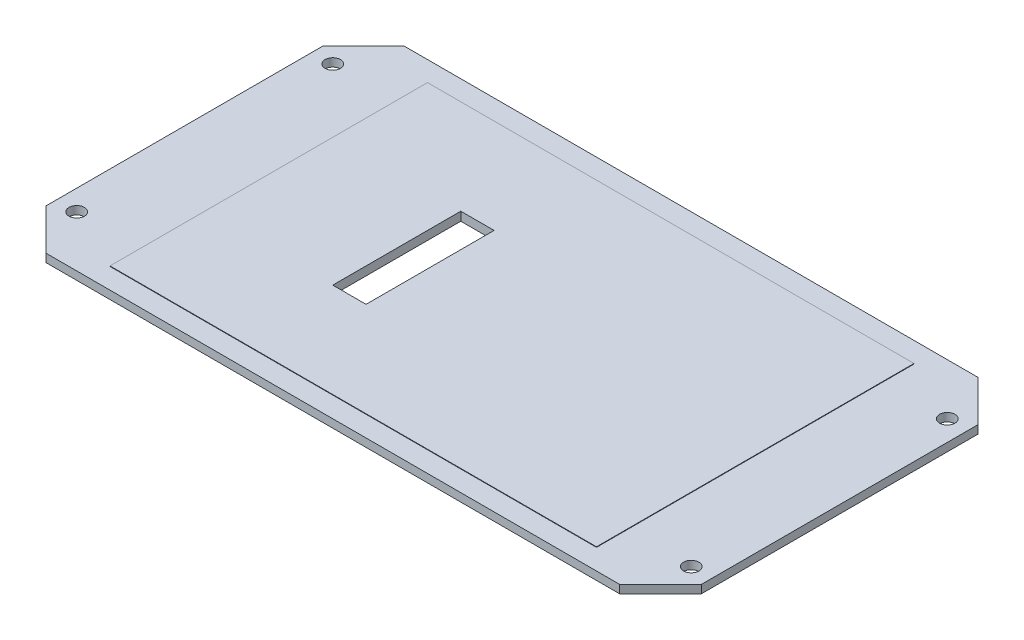
from build123d import *

# Parameters (mm, degrees)
SKETCH1_W                = 128
SKETCH1_H                = 70
BOSS_EXTRUDE1_DEPTH      = 1.6
CHAMFER1_SIZE            = 8
F_3_0_3_DIAMETER_HOLE1_D = 3
SKETCH4_W                = 95
SKETCH4_H                = 62
BOSS_EXTRUDE2_DEPTH      = 0.1
SKETCH5_W                = 6.5
SKETCH5_H                = 25
CUT_EXTRUDE1_DEPTH       = 2.7


with BuildPart() as part:
    # Sketch1 → Boss-Extrude1 (new body)
    with BuildSketch(Plane(origin=(0, -27, 0), x_dir=(1, 0, 0), z_dir=(0, 1, 0))):
        Rectangle(SKETCH1_W, SKETCH1_H)
    extrude(amount=BOSS_EXTRUDE1_DEPTH)

    # Chamfer1
    chamfer1_edges = [part.edges().sort_by_distance(p)[0] for p in [
        (64, -26.2, 35),
        (-64, -26.2, 35),
        (-64, -26.2, -35),
        (64, -26.2, -35),
    ]]
    chamfer(chamfer1_edges, length=CHAMFER1_SIZE)

    # Ø3.0 (3) Diameter Hole1 (through all)
    with Locations(Plane(origin=(0, -25.4, 0), x_dir=(1, 0, 0), z_dir=(0, 1, 0))):
        with Locations((-60, -25), (-60, 25), (60, 25), (60, -25)):
            Hole(F_3_0_3_DIAMETER_HOLE1_D / 2)

    # Sketch4 → Boss-Extrude2 (add)
    with BuildSketch(Plane(origin=(0, -25.4, 0), x_dir=(1, 0, 0), z_dir=(0, 1, 0))):
        Rectangle(SKETCH4_W, SKETCH4_H)
    extrude(amount=BOSS_EXTRUDE2_DEPTH)

    # Sketch5 → Cut-Extrude1 (cut, through all)
    with BuildSketch(Plane.XZ.offset(27)):
        with Locations((-19.25, 0)):
            Rectangle(SKETCH5_W, SKETCH5_H)
    extrude(amount=-CUT_EXTRUDE1_DEPTH, mode=Mode.SUBTRACT)


solid = part.part
